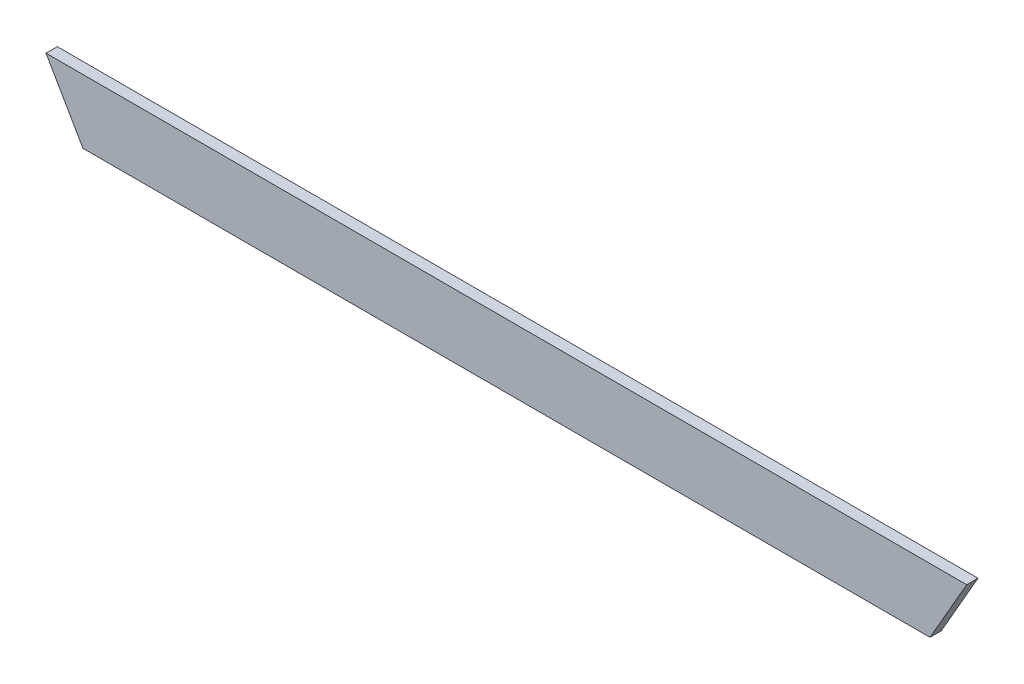
from build123d import *

# Parameters (mm, degrees)
BOSS_EXTRUDE1_DEPTH = 3


with BuildPart() as part:
    # Sketch1 → Boss-Extrude1 (new body)
    with BuildSketch(Plane.XY):
        Polygon((-660.185020783, 130.622118766), (-650.360564602, 113.62343356), (-425.139630486, 113.62343356), (-415.373000609, 130.622118766), align=None)
    extrude(amount=BOSS_EXTRUDE1_DEPTH)


solid = part.part
